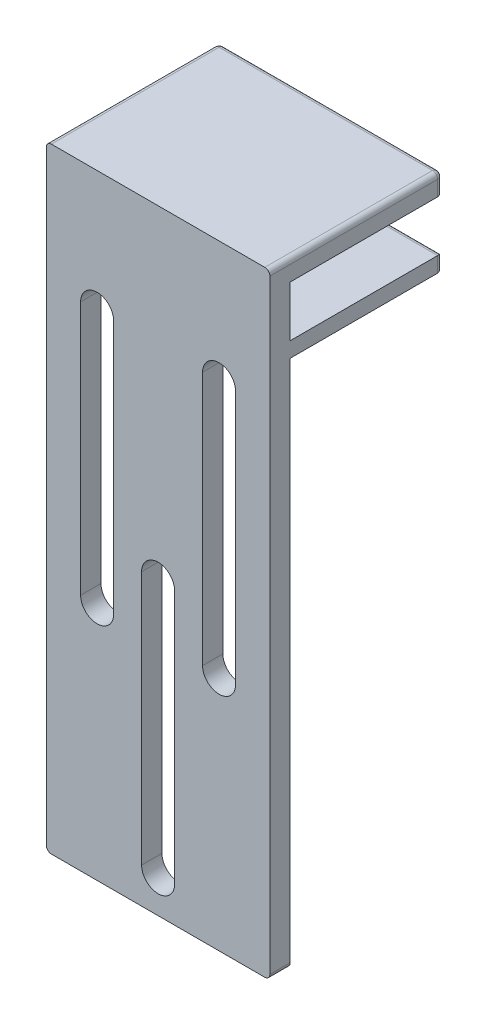
from build123d import *

# Parameters (mm, degrees)
EXTRUDE_1_DEPTH = 4
EXTRUDE_START   = -30
SKETCH_1_3_W    = 44
SKETCH_1_3_H    = 3
EXTRUDE_2_DEPTH = 30
FILLET_1_R      = 1


with BuildPart() as part:
    # 草图1 → 凸台-拉伸1 (new body)
    with BuildSketch(Plane.XY):
        with BuildLine():
            ThreePointArc((-22, 1), (-21.707106781, 0.292893219), (-21, 0))
            Line((-21, 0), (21, 0))
            ThreePointArc((21, 0), (21.707106781, 0.292893219), (22, 1))
            Line((22, 1), (22, 120))
            ThreePointArc((22, 120), (21.707106781, 120.707106781), (21, 121))
            Line((21, 121), (-21, 121))
            ThreePointArc((-21, 121), (-21.707106781, 120.707106781), (-22, 120))
            Line((-22, 120), (-22, 1))
        make_face()
        with BuildLine():
            ThreePointArc((3.25, 7), (0, 3.75), (-3.25, 7))
            Line((-3.25, 7), (-3.25, 57))
            ThreePointArc((-3.25, 57), (0, 60.25), (3.25, 57))
            Line((3.25, 57), (3.25, 7))
        make_face(mode=Mode.SUBTRACT)
        with BuildLine():
            ThreePointArc((-15.25, 97), (-12, 100.25), (-8.75, 97))
            Line((-8.75, 97), (-8.75, 47))
            ThreePointArc((-8.75, 47), (-12, 43.75), (-15.25, 47))
            Line((-15.25, 47), (-15.25, 97))
        make_face(mode=Mode.SUBTRACT)
        with BuildLine():
            Line((8.75, 47), (8.75, 97))
            ThreePointArc((8.75, 97), (12, 100.25), (15.25, 97))
            Line((15.25, 97), (15.25, 47))
            ThreePointArc((15.25, 47), (12, 43.75), (8.75, 47))
        make_face(mode=Mode.SUBTRACT)
    extrude(amount=EXTRUDE_1_DEPTH)

    # 草图1<3> → 凸台-拉伸2 (add)
    with BuildSketch(Plane.XY.offset(EXTRUDE_START)):
        with Locations((0, 105.5)):
            Rectangle(SKETCH_1_3_W, SKETCH_1_3_H)
        with BuildLine():
            Line((-22, 120), (-22, 117))
            Line((-22, 117), (22, 117))
            Line((22, 117), (22, 120))
            ThreePointArc((22, 120), (21.707106781, 120.707106781), (21, 121))
            Line((21, 121), (-21, 121))
            ThreePointArc((-21, 121), (-21.707106781, 120.707106781), (-22, 120))
        make_face()
    extrude(amount=EXTRUDE_2_DEPTH)

    # 圆角1
    fillet_1_edges = [part.edges().sort_by_distance(p)[0] for p in [
        (-22, 118.5, -30),
        (-21.707106781, 120.707106781, -30),
        (0, 121, -30),
        (21.707106781, 120.707106781, -30),
        (0, 104, -30),
        (0, 107, -30),
        (0, 117, -30),
        (22, 118.5, -30),
        (-22, 105.5, -30),
        (22, 105.5, -30),
    ]]
    fillet(fillet_1_edges, radius=FILLET_1_R)


solid = part.part
